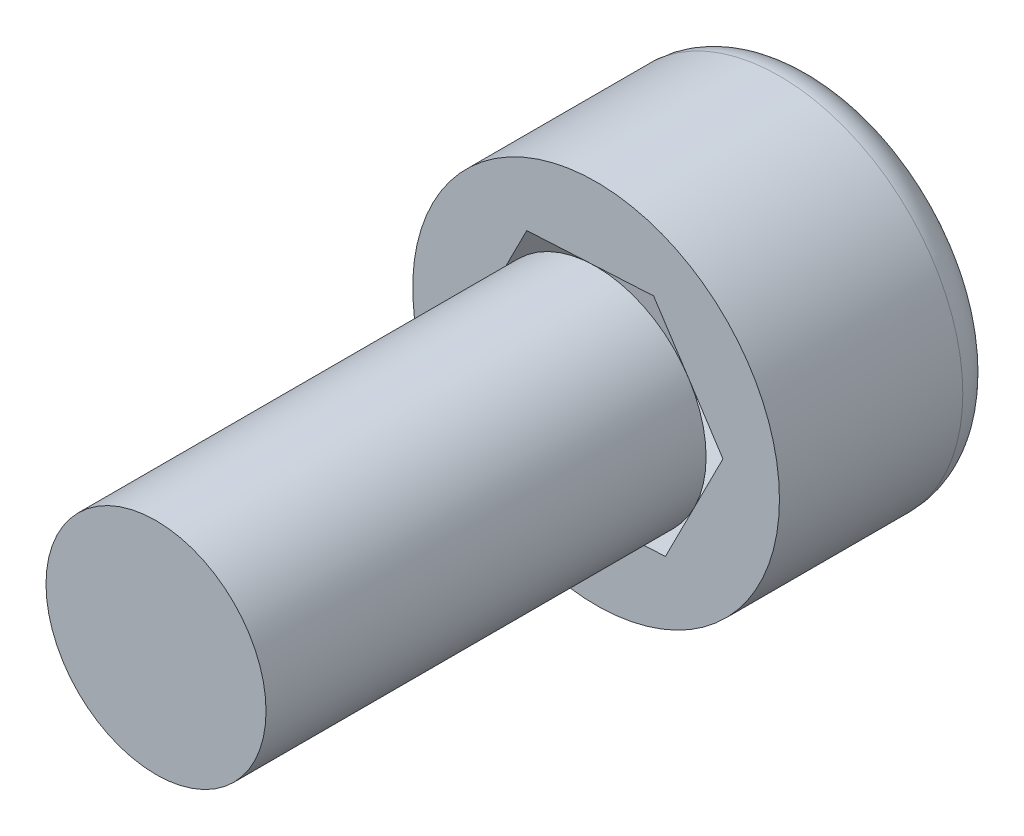
from build123d import *

# Parameters (mm, degrees)
SKETCH1_R           = 2.5
BOSS_EXTRUDE1_DEPTH = 3
SKETCH2_R           = 1.5
BOSS_EXTRUDE2_DEPTH = 6
CUT_EXTRUDE1_DEPTH  = 3
FILLET1_R           = 0.5


with BuildPart() as part:
    # Sketch1 → Boss-Extrude1 (new body)
    with BuildSketch(Plane.XY):
        Circle(SKETCH1_R)
    extrude(amount=BOSS_EXTRUDE1_DEPTH)

    # Sketch2 → Boss-Extrude2 (add)
    with BuildSketch(Plane.XY.offset(3)):
        Circle(SKETCH2_R)
    extrude(amount=BOSS_EXTRUDE2_DEPTH)

    # Sketch3 → Cut-Extrude1 (cut)
    with BuildSketch(Plane(origin=(0, 0, 0), x_dir=(-1, 0, 0), z_dir=(0, 0, -1))):
        Polygon((0.784462107, -1.544221229), (1.729565866, -0.092746502), (0.94510376, 1.451474727), (-0.784462107, 1.544221229), (-1.729565866, 0.092746502), (-0.94510376, -1.451474727), align=None)
    extrude(amount=-CUT_EXTRUDE1_DEPTH, mode=Mode.SUBTRACT)

    # Fillet1
    fillet1_edges = [part.edges().sort_by_distance(p)[0] for p in [
        (-2.5, 0, 0),
    ]]
    fillet(fillet1_edges, radius=FILLET1_R)


solid = part.part
